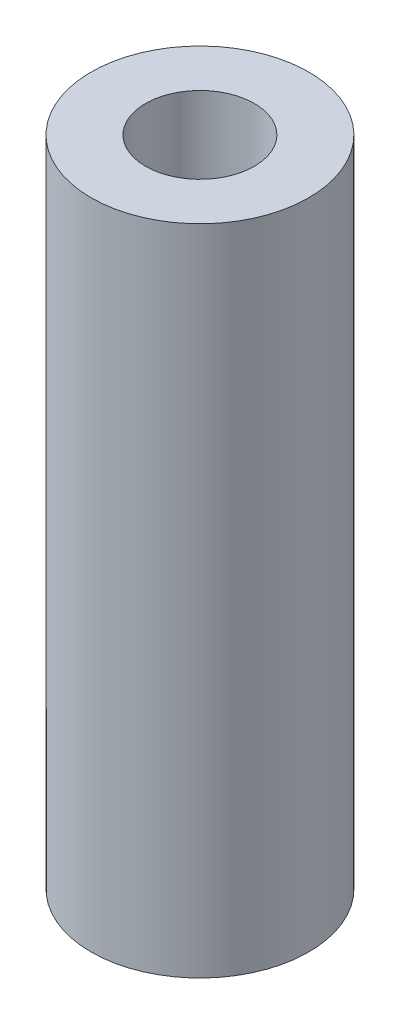
from build123d import *

# Parameters (mm, degrees)
ESQUISSE1_R        = 3
ESQUISSE1_R_2      = 1.5
BOSS_EXTRU_1_DEPTH = 18


with BuildPart() as part:
    # Esquisse1 → Boss.-Extru.1 (new body)
    with BuildSketch(Plane(origin=(0, 0, 0), x_dir=(1, 0, 0), z_dir=(0, 1, 0))):
        Circle(ESQUISSE1_R)
        Circle(ESQUISSE1_R_2, mode=Mode.SUBTRACT)
    extrude(amount=BOSS_EXTRU_1_DEPTH)


solid = part.part
